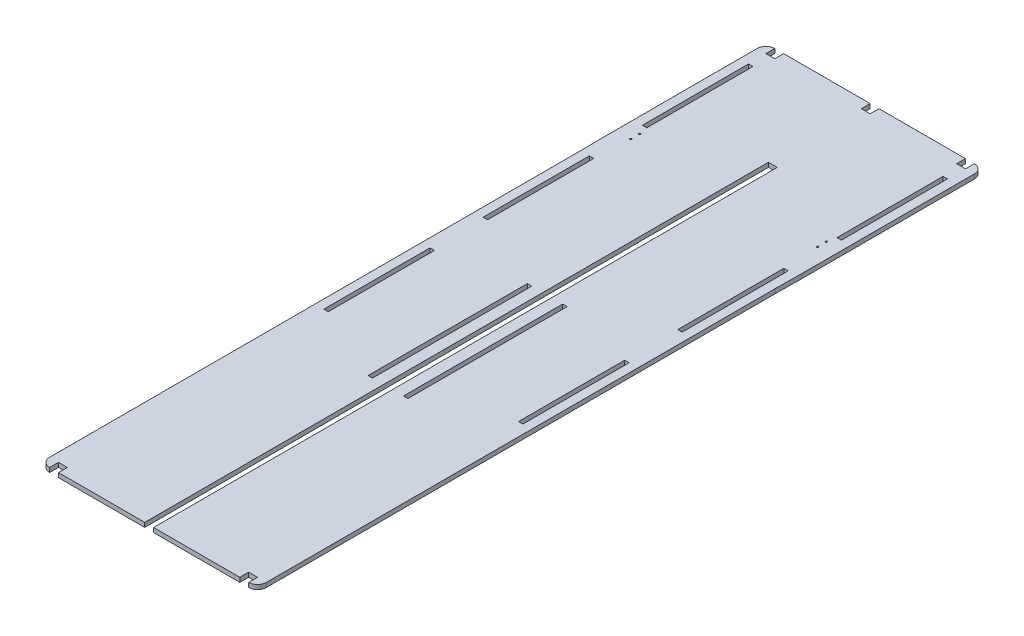
from build123d import *

# Parameters (mm, degrees)
SKETCH2_W           = 5
SKETCH2_H           = 120
BOSS_EXTRUDE1_DEPTH = 5
SKETCH3_R           = 1
SKETCH3_W           = 5
SKETCH3_H           = 180
CUT_EXTRUDE1_DEPTH  = 5
FILLET1_R           = 10
SKETCH4_W           = 10
SKETCH4_H           = 10
CUT_EXTRUDE2_DEPTH  = 10


with BuildPart() as part:
    # Sketch2 → Boss-Extrude1 (new body)
    with BuildSketch(Plane(origin=(0, 0, 0), x_dir=(1, 0, 0), z_dir=(0, 1, 0))):
        Polygon((0, 375), (0, 0), (0, -230), (10, -230), (15, -230), (117.5, -230), (117.5, 475), (127.5, 475), (127.5, -230), (230, -230), (235, -230), (245, -230), (245, -10), (245, 355), (245.3, 385), (245.3, 590), (245, 590), (0, 590), (-0.3, 590), (-0.3, 405), align=None)
        with Locations((12.5, 140)):
            Rectangle(SKETCH2_W, SKETCH2_H, mode=Mode.SUBTRACT)
        with Locations((232.5, 140)):
            Rectangle(SKETCH2_W, SKETCH2_H, mode=Mode.SUBTRACT)
        with Locations((12.5, 320)):
            Rectangle(SKETCH2_W, SKETCH2_H, mode=Mode.SUBTRACT)
        with Locations((12.5, 500)):
            Rectangle(SKETCH2_W, SKETCH2_H, mode=Mode.SUBTRACT)
        with Locations((232.5, 320)):
            Rectangle(SKETCH2_W, SKETCH2_H, mode=Mode.SUBTRACT)
        with Locations((232.5, 500)):
            Rectangle(SKETCH2_W, SKETCH2_H, mode=Mode.SUBTRACT)
    extrude(amount=BOSS_EXTRUDE1_DEPTH)

    # Sketch3 → Cut-Extrude1 (cut)
    with BuildSketch(Plane(origin=(0, 5, 0), x_dir=(1, 0, 0), z_dir=(0, 1, 0))):
        with Locations((17, 420)):
            Circle(SKETCH3_R)
        with Locations((17, 430)):
            Circle(SKETCH3_R)
        with Locations((102.5, 130)):
            Rectangle(SKETCH3_W, SKETCH3_H)
    cut_extrude1 = extrude(amount=-CUT_EXTRUDE1_DEPTH, mode=Mode.SUBTRACT)

    # Mirror1: Cut-Extrude1 across plane
    add(cut_extrude1.mirror(Plane.ZY.offset(-122.5)), mode=Mode.SUBTRACT)

    # Fillet1
    fillet1_edges = [part.edges().sort_by_distance(p)[0] for p in [
        (245, 2.5, 230),
        (0, 2.5, 230),
        (-0.3, 2.5, -590),
        (245.3, 2.5, -590),
    ]]
    fillet(fillet1_edges, radius=FILLET1_R)

    # Sketch4 → Cut-Extrude2 (cut)
    with BuildSketch(Plane(origin=(0, 5, 0), x_dir=(1, 0, 0), z_dir=(0, 1, 0))):
        with Locations((15, -225)):
            Rectangle(SKETCH4_W, SKETCH4_H)
        with Locations((230, -225)):
            Rectangle(SKETCH4_W, SKETCH4_H)
        with Locations((14.7, 585)):
            Rectangle(SKETCH4_W, SKETCH4_H)
        with Locations((230.3, 585)):
            Rectangle(SKETCH4_W, SKETCH4_H)
        with Locations((122.5, 585)):
            Rectangle(SKETCH4_W, SKETCH4_H)
    extrude(amount=-CUT_EXTRUDE2_DEPTH, mode=Mode.SUBTRACT)


solid = part.part
